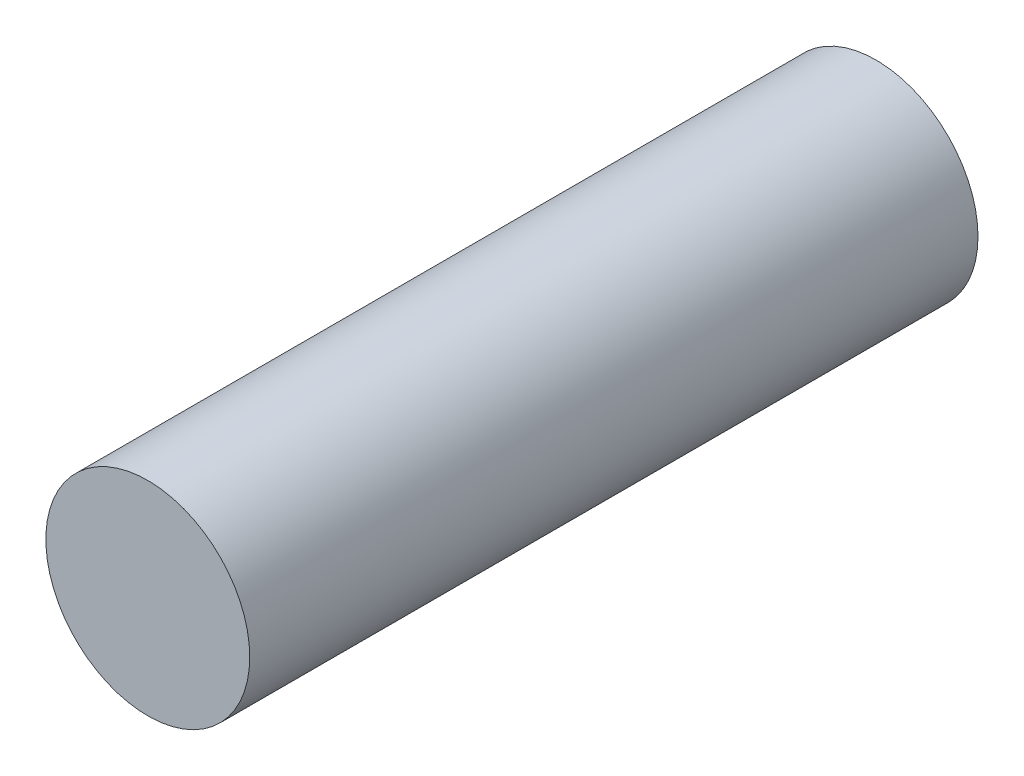
from build123d import *

# Parameters (mm, degrees)
SKETCH1_R           = 3.5
BOSS_EXTRUDE1_DEPTH = 25


with BuildPart() as part:
    # Sketch1 → Boss-Extrude1 (new body)
    with BuildSketch(Plane.XY):
        Circle(SKETCH1_R)
    extrude(amount=BOSS_EXTRUDE1_DEPTH)


solid = part.part
